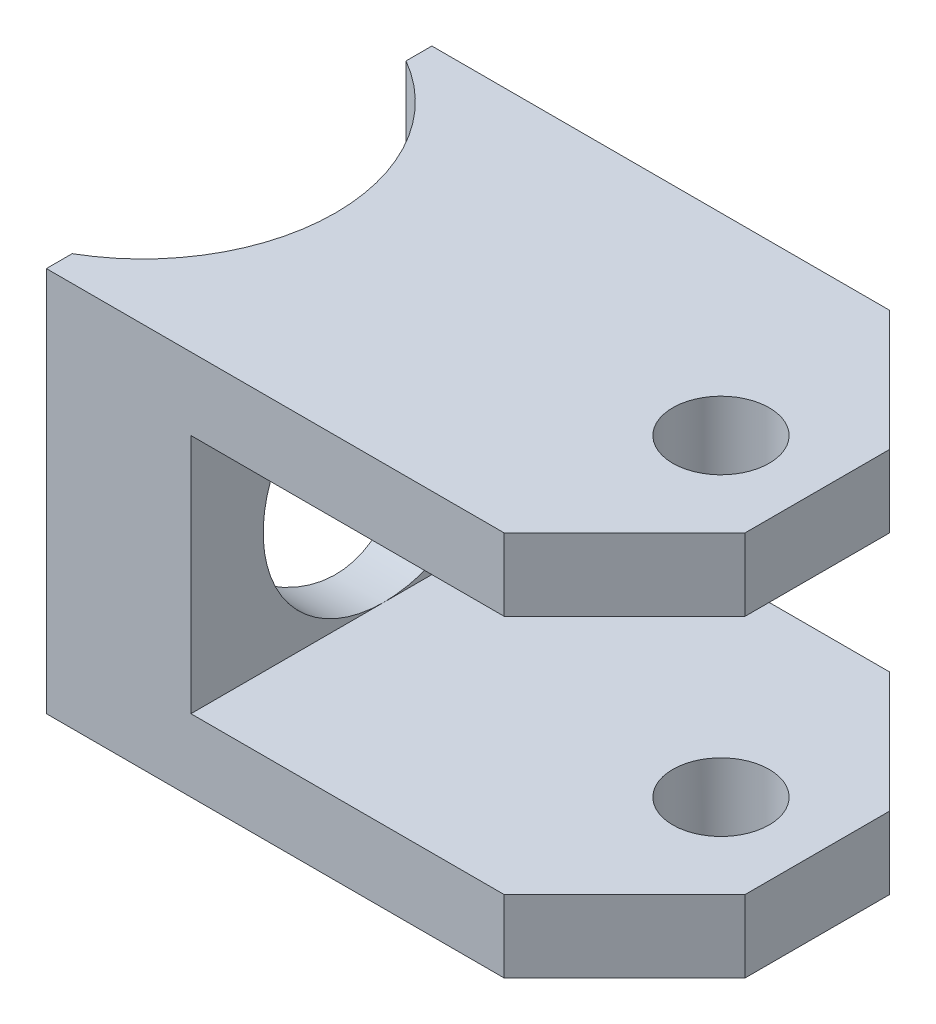
from build123d import *

# Parameters (mm, degrees)
BOSS_EXTRUDE1_DEPTH         = 12.7
F_1_4_0_25_DIAMETER_HOLE1_D = 6.35
CHAMFER1_SIZE               = 7.9375
SKETCH6_R                   = 7.9375
CUT_EXTRUDE1_DEPTH          = 10.525
SKETCH7_R                   = 12.7
CUT_EXTRUDE2_DEPTH          = 26.4


with BuildPart() as part:
    # Sketch1 → Boss-Extrude1 (new body, symmetric)
    with BuildSketch(Plane.XY):
        Polygon((6.35, 12.7), (44.45, 12.7), (44.45, 7.9375), (15.875, 7.9375), (15.875, -7.9375), (44.45, -7.9375), (44.45, -12.7), (6.35, -12.7), align=None)
    extrude(amount=BOSS_EXTRUDE1_DEPTH, both=True)

    # 1/4 (0.25) Diameter Hole1 (through all)
    with Locations(Plane(origin=(0, 12.7, 0), x_dir=(1, 0, 0), z_dir=(0, 1, 0))):
        with Locations((38.1, 0)):
            Hole(F_1_4_0_25_DIAMETER_HOLE1_D / 2)

    # Chamfer1
    chamfer1_edges = [part.edges().sort_by_distance(p)[0] for p in [
        (44.45, 10.31875, 12.7),
        (44.45, -10.31875, 12.7),
        (44.45, -10.31875, -12.7),
        (44.45, 10.31875, -12.7),
    ]]
    chamfer(chamfer1_edges, length=CHAMFER1_SIZE)

    # Sketch6 → Cut-Extrude1 (cut, through all)
    with BuildSketch(Plane(origin=(15.875, 0, 0), x_dir=(0, 0, -1), z_dir=(1, 0, 0))):
        Circle(SKETCH6_R)
    extrude(amount=-CUT_EXTRUDE1_DEPTH, mode=Mode.SUBTRACT)

    # Sketch7 → Cut-Extrude2 (cut, through all)
    with BuildSketch(Plane(origin=(0, 12.7, 0), x_dir=(1, 0, 0), z_dir=(0, 1, 0))):
        Circle(SKETCH7_R)
    extrude(amount=-CUT_EXTRUDE2_DEPTH, mode=Mode.SUBTRACT)


solid = part.part
